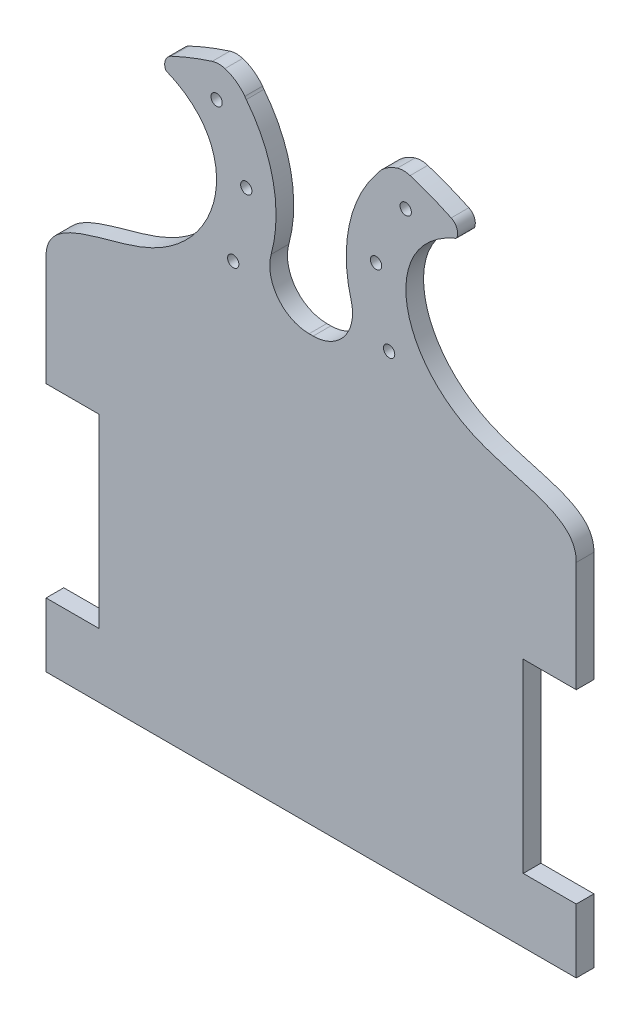
from build123d import *

# Parameters (mm, degrees)
SKETCH1_R           = 1.6
BOSS_EXTRUDE1_DEPTH = 5


with BuildPart() as part:
    # Sketch1 → Boss-Extrude1 (new body)
    with BuildSketch(Plane.XY):
        with BuildLine():
            Line((-75, -72.5), (-75, -90.625))
            Line((-75, -90.625), (75, -90.625))
            Line((75, -90.625), (75, -72.5))
            Line((75, -72.5), (60, -72.5))
            Line((60, -72.5), (60, -20))
            Line((60, -20), (75, -20))
            Line((75, -20), (75, 11.191407718))
            add(Edge.make_bspline(
                [(40.797859307, 73.529184669), (29.113413748, 68.584091893), (21.698756749, 49.837173387), (43.872198756, 22.538291001), (75.106478131, 22.355404036), (75, 11.191407718)],
                knots=[0.187825193, 0.187825193, 0.187825193, 0.187825193, 0.468621415, 0.712802941, 1, 1, 1, 1], degree=3))
            ThreePointArc((40.797859307, 73.529184669), (40.890658025, 73.576842128), (40.981293421, 73.628495399))
            ThreePointArc((40.981293421, 73.628495399), (41.118145392, 73.723771319), (41.210746684, 73.862447067))
            ThreePointArc((41.210746684, 73.862447067), (41.223041239, 76.211736408), (39.620297917, 77.929445758))
            ThreePointArc((39.620297917, 77.929445758), (33.882326143, 80.400449206), (27.994286118, 82.488788925))
            ThreePointArc((27.994286118, 82.488788925), (26.19343045, 82.774292897), (24.38900087, 82.512324293))
            ThreePointArc((24.38900087, 82.512324293), (20.964990276, 80.761920244), (18.364057527, 77.929445758))
            ThreePointArc((18.364057527, 77.929445758), (10.722602644, 61.575298771), (11.31305575, 43.533643593))
            ThreePointArc((11.31305575, 43.533643593), (9.427933785, 33.83519482), (0.573242194, 29.452498133))
            Line((0.573242194, 29.452498133), (-0.573242194, 29.452498133))
            ThreePointArc((-0.573242194, 29.452498133), (-9.427933785, 33.83519482), (-11.31305575, 43.533643593))
            ThreePointArc((-11.31305575, 43.533643593), (-10.722602644, 61.575298771), (-18.364057527, 77.929445758))
            ThreePointArc((-18.364057527, 77.929445758), (-18.578745667, 78.220711537), (-18.771416352, 78.526987162))
            ThreePointArc((-18.771416352, 78.526987162), (-21.256426114, 80.976047617), (-24.38900087, 82.512324293))
            ThreePointArc((-24.38900087, 82.512324293), (-26.19343045, 82.774292897), (-27.994286118, 82.488788925))
            ThreePointArc((-27.994286118, 82.488788925), (-33.882326143, 80.400449206), (-39.620297917, 77.929445758))
            ThreePointArc((-39.620297917, 77.929445758), (-41.223041239, 76.211736408), (-41.210746684, 73.862447067))
            ThreePointArc((-41.210746684, 73.862447067), (-41.118145392, 73.723771319), (-40.981293421, 73.628495399))
            add(Edge.make_bspline(
                [(-40.981293421, 73.628495399), (-29.036410535, 68.745777574), (-21.682695552, 49.95343828), (-43.802890071, 22.593157589), (-74.894409224, 22.356830762), (-75, 11.400592909)],
                knots=[0.184913023, 0.184913023, 0.184913023, 0.184913023, 0.468621415, 0.712802941, 0.998195008, 0.998195008, 0.998195008, 0.998195008], degree=3))
            Line((-75, 11.400592909), (-75, 11.191407718))
            Line((-75, 11.191407718), (-75, -20))
            Line((-75, -20), (-60, -20))
            Line((-60, -20), (-60, -72.5))
            Line((-60, -72.5), (-75, -72.5))
        make_face()
        with Locations((-22.052924911, 36.483296004)):
            Circle(SKETCH1_R, mode=Mode.SUBTRACT)
        with Locations((-18.364057527, 56.292076909)):
            Circle(SKETCH1_R, mode=Mode.SUBTRACT)
        with Locations((-26.753522246, 73.691170186)):
            Circle(SKETCH1_R, mode=Mode.SUBTRACT)
        with Locations((22.052924911, 36.483296004)):
            Circle(SKETCH1_R, mode=Mode.SUBTRACT)
        with Locations((18.364057527, 56.292076909)):
            Circle(SKETCH1_R, mode=Mode.SUBTRACT)
        with Locations((26.753522246, 73.691170186)):
            Circle(SKETCH1_R, mode=Mode.SUBTRACT)
    extrude(amount=BOSS_EXTRUDE1_DEPTH)


solid = part.part
